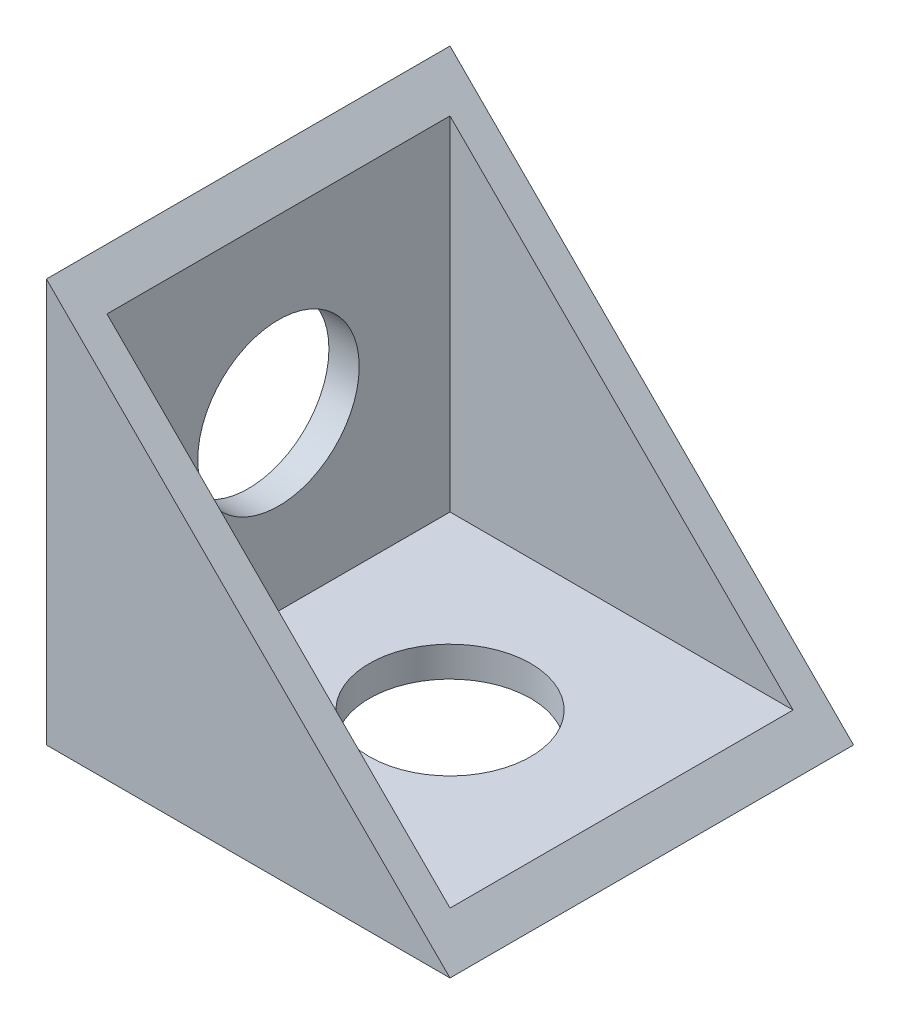
from build123d import *

# Parameters (mm, degrees)
BOSS_EXTRUDE1_DEPTH     = 10
SKETCH3_R               = 4
CUT_EXTRUDE1_DEPTH      = 20
SKETCH4_R               = 4
CUT_EXTRUDE2_DEPTH      = 10
SKETCH5_W               = 17
SKETCH5_H               = 18.5
CUT_EXTRUDE3_DEPTH      = 10
CUT_EXTRUDE3_DEPTH_BACK = 8.5


with BuildPart() as part:
    # Sketch1 → Boss-Extrude1 (new body, symmetric)
    with BuildSketch(Plane.XY):
        Polygon((-10, 0), (10, 0), (-10, 20), align=None)
    extrude(amount=BOSS_EXTRUDE1_DEPTH, both=True)

    # Sketch3 → Cut-Extrude1 (cut)
    with BuildSketch(Plane(origin=(0, 0, 0), x_dir=(1, 0, 0), z_dir=(0, 1, 0))):
        Circle(SKETCH3_R)
    extrude(amount=CUT_EXTRUDE1_DEPTH, mode=Mode.SUBTRACT)

    # Sketch4 → Cut-Extrude2 (cut, symmetric)
    with BuildSketch(Plane(origin=(0, 0, 0), x_dir=(0, 0, -1), z_dir=(1, 0, 0))):
        with Locations((0, 10)):
            Circle(SKETCH4_R)
    extrude(amount=CUT_EXTRUDE2_DEPTH, both=True, mode=Mode.SUBTRACT)

    # Sketch5 → Cut-Extrude3 (cut, two sides)
    with BuildSketch(Plane(origin=(0, 0, 0), x_dir=(0, 0, -1), z_dir=(1, 0, 0))) as cut_extrude3_sk:
        with Locations((0, 10.75)):
            Rectangle(SKETCH5_W, SKETCH5_H)
    extrude(amount=CUT_EXTRUDE3_DEPTH, mode=Mode.SUBTRACT)
    extrude(cut_extrude3_sk.sketch, amount=-CUT_EXTRUDE3_DEPTH_BACK, mode=Mode.SUBTRACT)


solid = part.part
